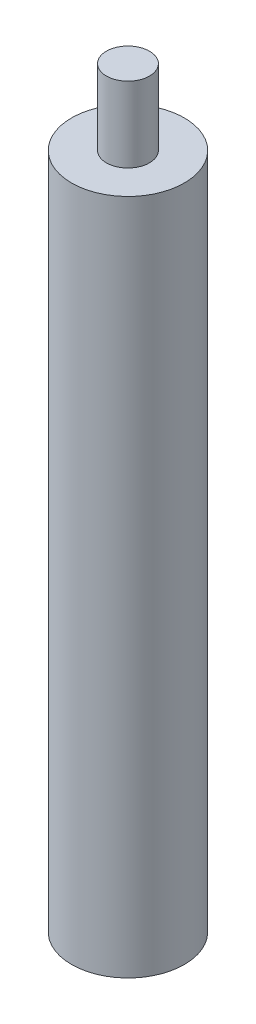
from build123d import *

# Parameters (mm, degrees)
SKETCH1_R           = 9.525
BOSS_EXTRUDE1_DEPTH = 114.3
SKETCH2_R           = 3.63855
BOSS_EXTRUDE2_DEPTH = 12.7
SKETCH3_R           = 3.51155
CUT_EXTRUDE1_DEPTH  = 12.7


with BuildPart() as part:
    # Sketch1 → Boss-Extrude1 (new body)
    with BuildSketch(Plane(origin=(0, 0, 0), x_dir=(1, 0, 0), z_dir=(0, 1, 0))):
        Circle(SKETCH1_R)
    extrude(amount=BOSS_EXTRUDE1_DEPTH)

    # Sketch2 → Boss-Extrude2 (add)
    with BuildSketch(Plane(origin=(0, 114.3, 0), x_dir=(1, 0, 0), z_dir=(0, 1, 0))):
        Circle(SKETCH2_R)
    extrude(amount=BOSS_EXTRUDE2_DEPTH)

    # Sketch3 → Cut-Extrude1 (cut)
    with BuildSketch(Plane.XZ):
        Circle(SKETCH3_R)
    extrude(amount=-CUT_EXTRUDE1_DEPTH, mode=Mode.SUBTRACT)


solid = part.part
